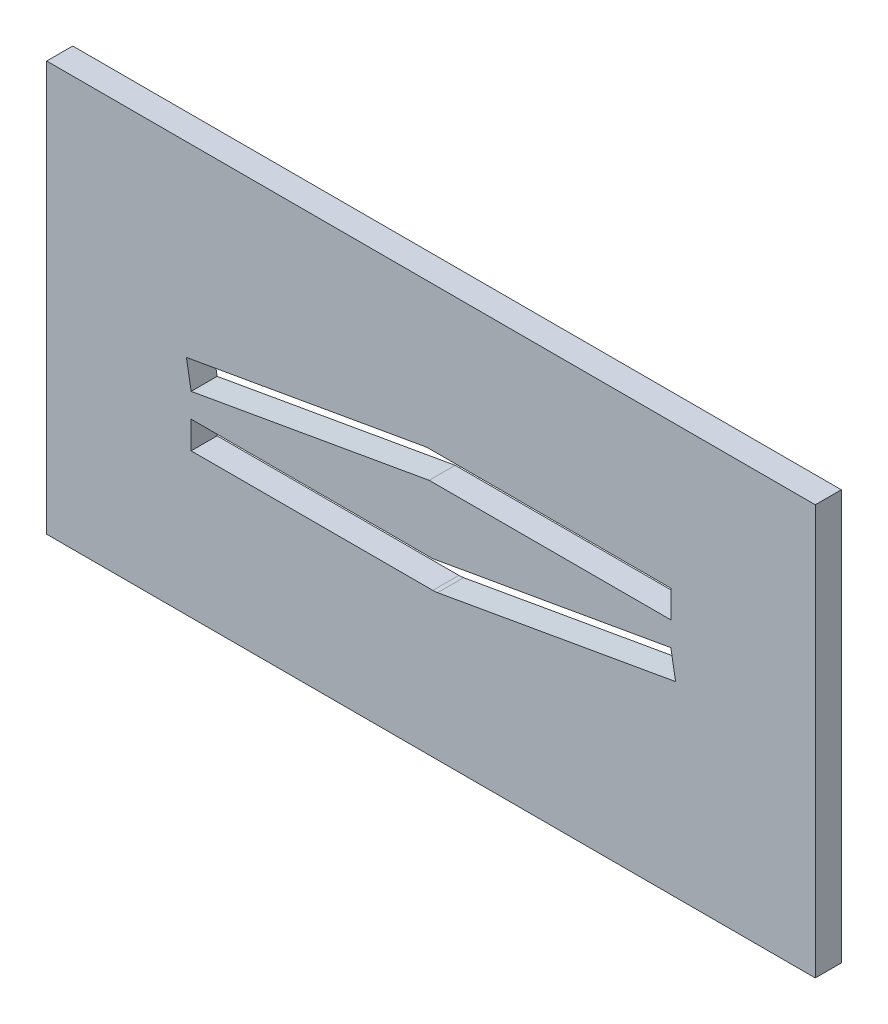
from build123d import *

# Parameters (mm, degrees)
SKETCH1_W           = 79.809734904
SKETCH1_H           = 42.557787138
BOSS_EXTRUDE1_DEPTH = 2.7


with BuildPart() as part:
    # Sketch1 → Boss-Extrude1 (new body)
    with BuildSketch(Plane.XY):
        Rectangle(SKETCH1_W, SKETCH1_H)
        Polygon((-24.904867452, -0.928893569), (-0.190628486, 3.428893569), (24.904867452, 3.428893569), (24.904867452, 6.278893569), (-0.190628486, 6.278893569), (-0.685525793, 6.235595665), (-25.399764759, 1.877808527), align=None, mode=Mode.SUBTRACT)
        Polygon((-24.904867452, -3.428893569), (0.190628486, -3.428893569), (24.904867452, 0.928893569), (25.399764759, -1.877808527), (0.685525793, -6.235595665), (0.190628486, -6.278893569), (-24.904867452, -6.278893569), align=None, mode=Mode.SUBTRACT)
    extrude(amount=BOSS_EXTRUDE1_DEPTH)


solid = part.part
